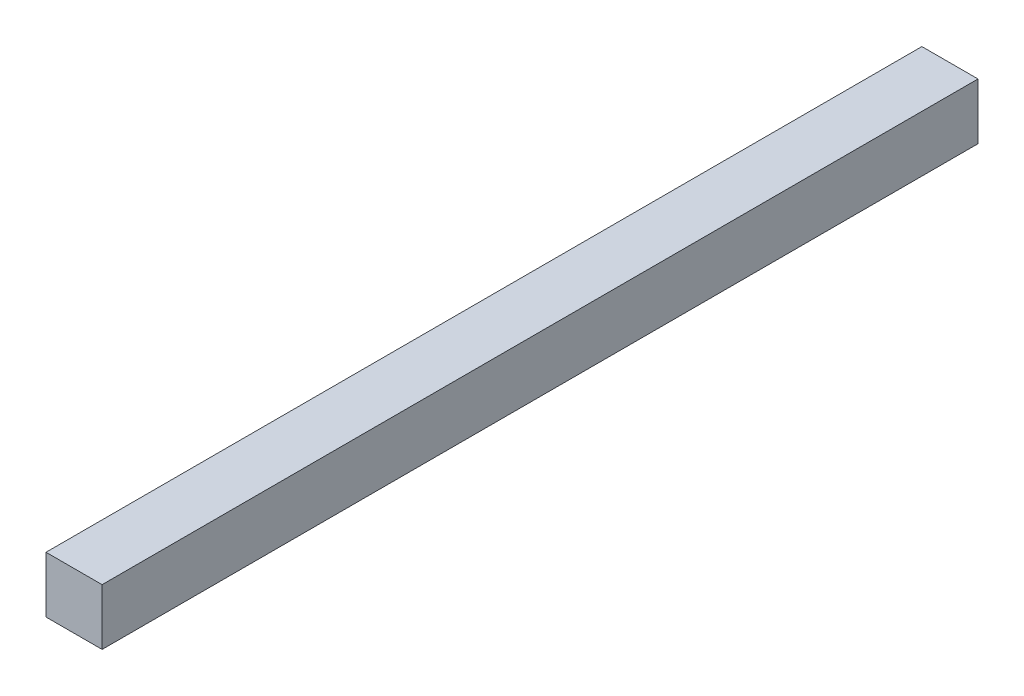
from build123d import *

# Parameters (mm, degrees)
SKETCH_1_W      = 20
SKETCH_1_H      = 20
EXTRUDE_1_DEPTH = 312.2


with BuildPart() as part:
    # 草图1 → 凸台-拉伸1 (new body)
    with BuildSketch(Plane.XY):
        Rectangle(SKETCH_1_W, SKETCH_1_H)
    extrude(amount=EXTRUDE_1_DEPTH)


solid = part.part
